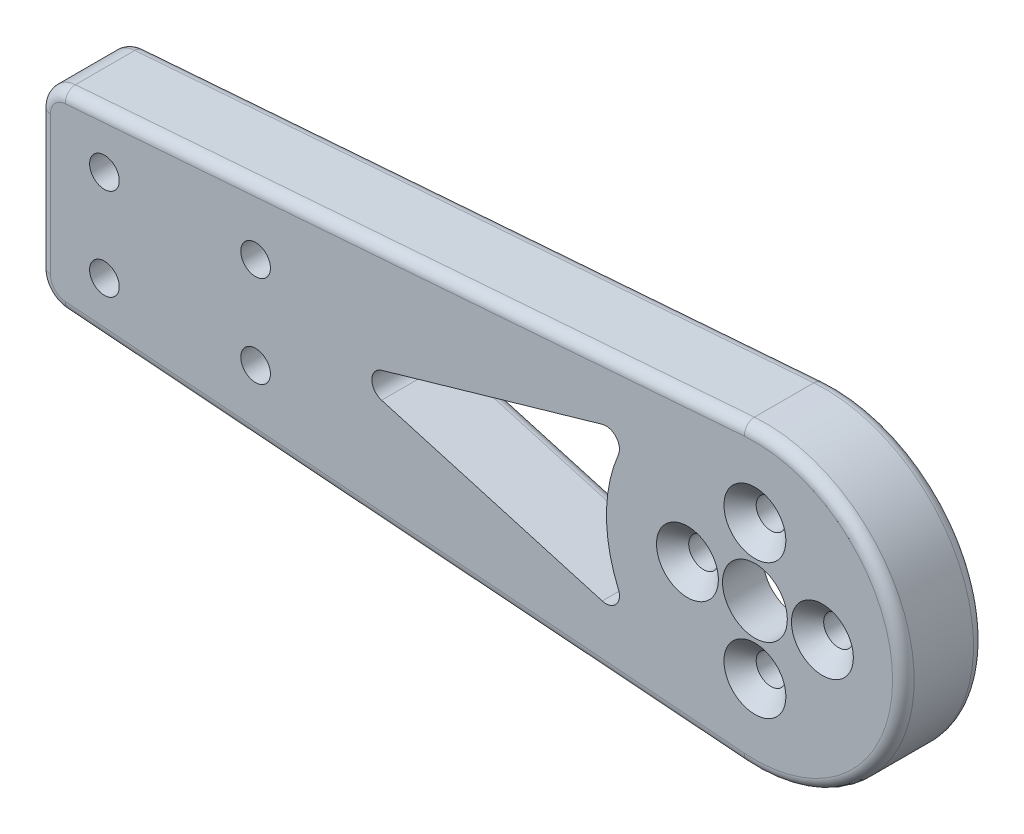
from build123d import *

# Parameters (mm, degrees)
SKETCH1_R                                            = 6
BOSS_EXTRUDE1_DEPTH                                  = 7.5
SKETCH2_R                                            = 20
CUT_EXTRUDE1_DEPTH                                   = 7.5
CUT_EXTRUDE3_DEPTH                                   = 16
CUT_EXTRUDE5_DEPTH                                   = 10
FILLET4_R                                            = 2
CSK_FOR_M5_HEX_SOCKET_COUNTERSUNK_HEAD_S_D           = 5.5
CSK_FOR_M5_HEX_SOCKET_COUNTERSUNK_HEAD_S_CSINK_D     = 11.47
CSK_FOR_M5_HEX_SOCKET_COUNTERSUNK_HEAD_S_CSINK_ANGLE = 90
CSK_FOR_M5_HEX_SOCKET_COUNTERSUNK_HE_2_D             = 5.5
CSK_FOR_M5_HEX_SOCKET_COUNTERSUNK_HE_2_CSINK_D       = 11.47
CSK_FOR_M5_HEX_SOCKET_COUNTERSUNK_HE_2_CSINK_ANGLE   = 90
LPATTERN1_COUNT                                      = 2
LPATTERN1_PITCH                                      = 28
LPATTERN1_COUNT_DIR2                                 = 2
LPATTERN1_PITCH_DIR2                                 = 17


with BuildPart() as part:
    # Sketch1 → Boss-Extrude1 (new body, symmetric)
    with BuildSketch(Plane.XY):
        with BuildLine():
            Line((-2.085935445, -27.420774484), (-127.87926099, -17.851505873))
            ThreePointArc((-127.87926099, -17.851505873), (-131.167172272, -16.264711408), (-132.5, -12.865910513))
            Line((-132.5, -12.865910513), (-132.5, 12.865910513))
            ThreePointArc((-132.5, 12.865910513), (-131.167172272, 16.264711408), (-127.87926099, 17.851505873))
            Line((-127.87926099, 17.851505873), (-2.085935445, 27.420774484))
            ThreePointArc((-2.085935445, 27.420774484), (27.5, 0), (-2.085935445, -27.420774484))
        make_face()
        Circle(SKETCH1_R, mode=Mode.SUBTRACT)
    extrude(amount=BOSS_EXTRUDE1_DEPTH, both=True)

    # Sketch2 → Cut-Extrude1 (cut)
    with BuildSketch(Plane(origin=(0, 0, -7.5), x_dir=(-1, 0, 0), z_dir=(0, 0, -1))):
        Circle(SKETCH2_R)
    extrude(amount=-CUT_EXTRUDE1_DEPTH, mode=Mode.SUBTRACT)

    # Sketch4 → Cut-Extrude3 (cut, through all)
    with BuildSketch(Plane(origin=(0, 0, -7.5), x_dir=(-1, 0, 0), z_dir=(0, 0, -1))):
        with BuildLine():
            Line((28.288155347, 14.168192599), (69.155438709, 2.40241658))
            ThreePointArc((69.155438709, 2.40241658), (70.963777971, 0), (69.155438709, -2.40241658))
            Line((69.155438709, -2.40241658), (28.288155347, -14.168192599))
            ThreePointArc((28.288155347, -14.168192599), (25.723674948, -13.42183958), (25.296786724, -10.785294684))
            ThreePointArc((25.296786724, -10.785294684), (27.5, 0), (25.296786724, 10.785294684))
            ThreePointArc((25.296786724, 10.785294684), (25.723674948, 13.42183958), (28.288155347, 14.168192599))
        make_face()
    extrude(amount=-CUT_EXTRUDE3_DEPTH, mode=Mode.SUBTRACT)

    # Sketch6 → Cut-Extrude5 (cut)
    with BuildSketch(Plane(origin=(0, 0, -7.5), x_dir=(-1, 0, 0), z_dir=(0, 0, -1))):
        with BuildLine():
            Line((58.631606678, 10.635344041), (79.355521547, 4.668885776))
            ThreePointArc((79.355521547, 4.668885776), (81.550652962, 5.073910075), (82.547182285, 7.071302356))
            Line((82.547182285, 7.071302356), (82.547182285, 11.461264354))
            ThreePointArc((82.547182285, 11.461264354), (81.880768421, 13.160664802), (80.23681278, 13.954062035))
            Line((80.23681278, 13.954062035), (59.512897911, 15.530558301))
            ThreePointArc((59.512897911, 15.530558301), (56.862822486, 13.480717442), (58.631606678, 10.635344041))
        make_face()
        with BuildLine():
            Line((82.547182285, -7.071302356), (82.547182285, -11.461264354))
            ThreePointArc((82.547182285, -11.461264354), (81.880768421, -13.160664802), (80.23681278, -13.954062035))
            Line((80.23681278, -13.954062035), (59.512897911, -15.530558301))
            ThreePointArc((59.512897911, -15.530558301), (56.862822486, -13.480717442), (58.631606678, -10.635344041))
            Line((58.631606678, -10.635344041), (79.355521547, -4.668885776))
            ThreePointArc((79.355521547, -4.668885776), (81.550652962, -5.073910075), (82.547182285, -7.071302356))
        make_face()
    extrude(amount=-CUT_EXTRUDE5_DEPTH, mode=Mode.SUBTRACT)

    # Fillet4
    fillet4_edges = [part.edges().sort_by_distance(p)[0] for p in [
        (-131.167172272, 16.264711408, 7.5),
        (-132.5, 0, 7.5),
        (-131.167172272, -16.264711408, 7.5),
        (-64.982598218, -22.636140179, 7.5),
        (-70.963777971, 0, -7.5),
        (-48.721797028, 8.285304589, -7.5),
        (-25.723674948, 13.42183958, -7.5),
        (-27.5, 0, -7.5),
        (-25.723674948, -13.42183958, -7.5),
        (-48.721797028, -8.285304589, -7.5),
        (27.5, 0, 7.5),
        (-81.880768421, 13.160664802, -7.5),
        (-69.874855346, 14.742310168, -7.5),
        (-56.862822486, 13.480717442, -7.5),
        (-68.993564112, 7.652114908, -7.5),
        (-81.550652962, 5.073910075, -7.5),
        (-82.547182285, 9.266283355, -7.5),
        (-64.982598218, -22.636140179, -7.5),
        (-81.550652962, -5.073910075, -7.5),
        (-68.993564112, -7.652114908, -7.5),
        (-56.862822486, -13.480717442, -7.5),
        (-69.874855346, -14.742310168, -7.5),
        (-81.880768421, -13.160664802, -7.5),
        (-82.547182285, -9.266283355, -7.5),
        (-131.167172272, -16.264711408, -7.5),
        (-132.5, 0, -7.5),
        (-131.167172272, 16.264711408, -7.5),
        (-64.982598218, 22.636140179, -7.5),
        (27.5, 0, -7.5),
        (-64.982598218, 22.636140179, 7.5),
    ]]
    fillet(fillet4_edges, radius=FILLET4_R)

    # CSK for M5 Hex Socket Countersunk Head S (through all)
    with Locations(Plane.XY.offset(7.5)):
        with Locations((-12.5, 0), (0, 12.5), (12.5, 0), (0, -12.5)):
            CounterSinkHole(CSK_FOR_M5_HEX_SOCKET_COUNTERSUNK_HEAD_S_D / 2, CSK_FOR_M5_HEX_SOCKET_COUNTERSUNK_HEAD_S_CSINK_D / 2, counter_sink_angle=CSK_FOR_M5_HEX_SOCKET_COUNTERSUNK_HEAD_S_CSINK_ANGLE)

    # CSK for M5 Hex Socket Countersunk He 2 (through all)
    with Locations(Plane(origin=(0, 0, -7.5), x_dir=(-1, 0, 0), z_dir=(0, 0, -1))):
        with Locations((92.5, 8.5)):
            csk_for_m5_hex_socket_countersunk_he_2 = CounterSinkHole(CSK_FOR_M5_HEX_SOCKET_COUNTERSUNK_HE_2_D / 2, CSK_FOR_M5_HEX_SOCKET_COUNTERSUNK_HE_2_CSINK_D / 2, counter_sink_angle=CSK_FOR_M5_HEX_SOCKET_COUNTERSUNK_HE_2_CSINK_ANGLE)

    # LPattern1: CSK for M5 Hex Socket Countersunk He 2 2 × 2
    with Locations(*[(-i * LPATTERN1_PITCH, -j * LPATTERN1_PITCH_DIR2, 0) for i in range(LPATTERN1_COUNT) for j in range(LPATTERN1_COUNT_DIR2) if (i, j) != (0, 0)]):
        add(csk_for_m5_hex_socket_countersunk_he_2, mode=Mode.SUBTRACT)


solid = part.part
